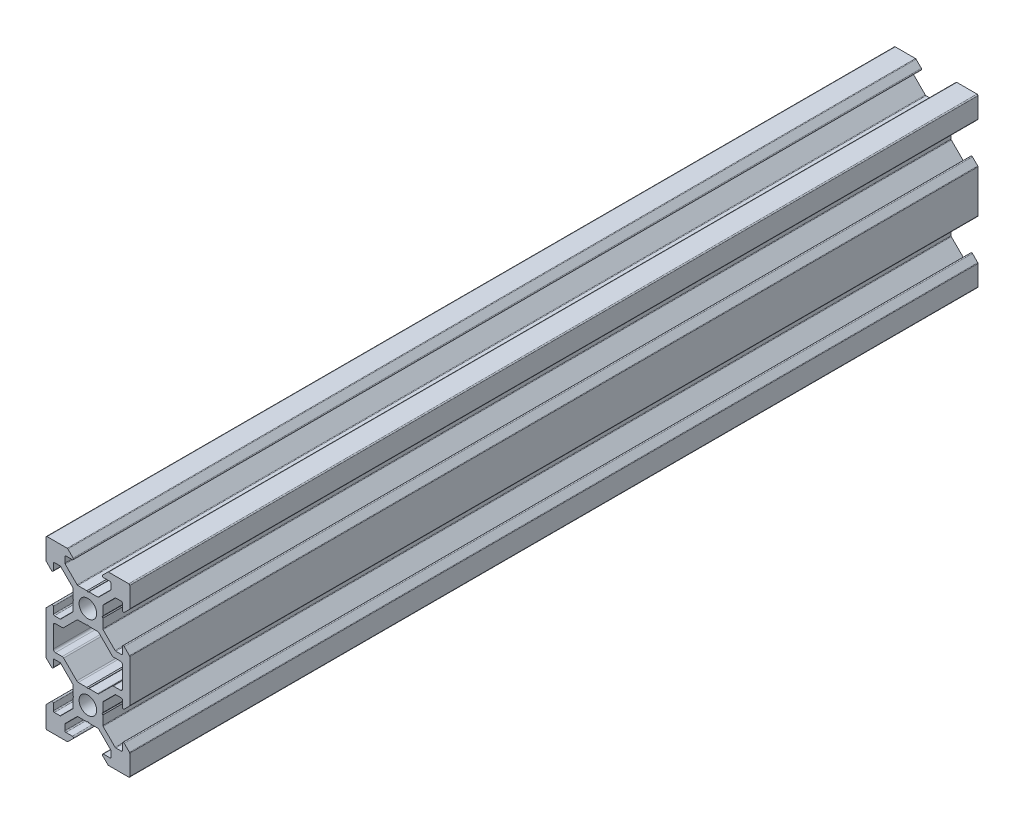
from build123d import *

# Parameters (mm, degrees)
SKETCH1_R           = 2.1
BOSS_EXTRUDE1_DEPTH = 202.56
FILLET1_R           = 0.25
FILLET2_R           = 0.5
CUT_EXTRUDE1_DEPTH  = 203.56


with BuildPart() as part:
    # Sketch1 → Boss-Extrude1 (new body)
    with BuildSketch(Plane.XY):
        Polygon((3.560660172, -2.5), (3.560660172, 2.5), (6.560660172, 5.5), (8.252142372, 5.5), (8.252142372, 3.1), (10, 4.847857628), (10, 10), (4.847857628, 10), (3.1, 8.252142372), (5.5, 8.252142372), (5.5, 6.560660172), (2.5, 3.560660172), (-2.5, 3.560660172), (-5.5, 6.560660172), (-5.5, 8.252142372), (-3.1, 8.252142372), (-4.847857628, 10), (-10, 10), (-10, 4.847857628), (-8.252142372, 3.1), (-8.252142372, 5.5), (-6.560660172, 5.5), (-3.560660172, 2.5), (-3.560660172, -2.5), (-6.560660172, -5.5), (-8.252142372, -5.5), (-8.252142372, -3.1), (-10, -4.847857628), (-10, -7), (-10, -13), (-10, -15.152142372), (-8.252142372, -16.9), (-8.252142372, -14.5), (-6.560660172, -14.5), (-3.560660172, -17.5), (-3.560660172, -22.5), (-6.560660172, -25.5), (-8.252142372, -25.5), (-8.252142372, -23.1), (-10, -24.847857628), (-10, -30), (-4.847857628, -30), (-3.1, -28.252142372), (-5.5, -28.252142372), (-5.5, -26.560660172), (-2.5, -23.560660172), (2.5, -23.560660172), (5.5, -26.560660172), (5.5, -28.252142372), (3.1, -28.252142372), (4.847857628, -30), (10, -30), (10, -24.847857628), (8.252142372, -23.1), (8.252142372, -25.5), (6.560660172, -25.5), (3.560660172, -22.5), (3.560660172, -17.5), (6.560660172, -14.5), (8.252142372, -14.5), (8.252142372, -16.9), (10, -15.152142372), (10, -13), (10, -7), (10, -4.847857628), (8.252142372, -3.1), (8.252142372, -5.5), (6.560660172, -5.5), align=None)
        Circle(SKETCH1_R, mode=Mode.SUBTRACT)
        with Locations((0, -20)):
            Circle(SKETCH1_R, mode=Mode.SUBTRACT)
        Polygon((2.5, -3.560660172), (-2.5, -3.560660172), (-5.5, -6.560660172), (-5.939339828, -7), (-8.252142372, -7), (-8.252142372, -13), (-5.939339828, -13), (-5.5, -13.439339828), (-2.5, -16.439339828), (2.5, -16.439339828), (5.5, -13.439339828), (5.939339828, -13), (8.252142372, -13), (8.252142372, -7), (5.939339828, -7), (5.5, -6.560660172), align=None, mode=Mode.SUBTRACT)
    extrude(amount=BOSS_EXTRUDE1_DEPTH)

    # Fillet1
    fillet1_edges = [part.edges().sort_by_distance(p)[0] for p in [
        (5.5, 6.560660172, 101.28),
        (5.5, 8.252142372, 101.28),
        (3.1, 8.252142372, 101.28),
        (4.847857628, 10, 101.28),
        (10, 10, 101.28),
        (10, 4.847857628, 101.28),
        (8.252142372, 3.1, 101.28),
        (8.252142372, 5.5, 101.28),
        (6.560660172, 5.5, 101.28),
        (3.560660172, 2.5, 101.28),
        (3.560660172, -2.5, 101.28),
        (6.560660172, -5.5, 101.28),
        (8.252142372, -5.5, 101.28),
        (8.252142372, -3.1, 101.28),
        (10, -4.847857628, 101.28),
        (10, -15.152142372, 101.28),
        (8.252142372, -16.9, 101.28),
        (8.252142372, -14.5, 101.28),
        (6.560660172, -14.5, 101.28),
        (3.560660172, -17.5, 101.28),
        (3.560660172, -22.5, 101.28),
        (6.560660172, -25.5, 101.28),
        (8.252142372, -25.5, 101.28),
        (8.252142372, -23.1, 101.28),
        (10, -24.847857628, 101.28),
        (10, -30, 101.28),
        (4.847857628, -30, 101.28),
        (3.1, -28.252142372, 101.28),
        (5.5, -28.252142372, 101.28),
        (5.5, -26.560660172, 101.28),
        (2.5, -23.560660172, 101.28),
        (-2.5, -23.560660172, 101.28),
        (-5.5, -26.560660172, 101.28),
        (-5.5, -28.252142372, 101.28),
        (-3.1, -28.252142372, 101.28),
        (-4.847857628, -30, 101.28),
        (-10, -30, 101.28),
        (-10, -24.847857628, 101.28),
        (-8.252142372, -23.1, 101.28),
        (-8.252142372, -25.5, 101.28),
        (-6.560660172, -25.5, 101.28),
        (-3.560660172, -22.5, 101.28),
        (-3.560660172, -17.5, 101.28),
        (-6.560660172, -14.5, 101.28),
        (-8.252142372, -14.5, 101.28),
        (-8.252142372, -16.9, 101.28),
        (-10, -15.152142372, 101.28),
        (-10, -4.847857628, 101.28),
        (-8.252142372, -3.1, 101.28),
        (-8.252142372, -5.5, 101.28),
        (-6.560660172, -5.5, 101.28),
        (-3.560660172, -2.5, 101.28),
        (-3.560660172, 2.5, 101.28),
        (-6.560660172, 5.5, 101.28),
        (-8.252142372, 5.5, 101.28),
        (-8.252142372, 3.1, 101.28),
        (-10, 4.847857628, 101.28),
        (-10, 10, 101.28),
        (-4.847857628, 10, 101.28),
        (-3.1, 8.252142372, 101.28),
        (-5.5, 8.252142372, 101.28),
        (-5.5, 6.560660172, 101.28),
        (-2.5, 3.560660172, 101.28),
        (2.5, 3.560660172, 101.28),
    ]]
    fillet(fillet1_edges, radius=FILLET1_R)

    # Fillet2
    fillet2_edges = [part.edges().sort_by_distance(p)[0] for p in [
        (-2.5, -3.560660172, 101.28),
        (-5.939339828, -7, 101.28),
        (-8.252142372, -7, 101.28),
        (-8.252142372, -13, 101.28),
        (-5.939339828, -13, 101.28),
        (-2.5, -16.439339828, 101.28),
        (2.5, -16.439339828, 101.28),
        (5.939339828, -13, 101.28),
        (8.252142372, -13, 101.28),
        (8.252142372, -7, 101.28),
        (5.939339828, -7, 101.28),
        (2.5, -3.560660172, 101.28),
    ]]
    fillet(fillet2_edges, radius=FILLET2_R)

    # Sketch2 → Cut-Extrude1 (cut, through all)
    with BuildSketch(Plane.XY.offset(202.56)):
        Polygon((0, 3.398953432), (-0.242280927, 3.560660172), (0.242280927, 3.560660172), align=None)
        Polygon((0, -3.398953432), (0.242280927, -3.560660172), (-0.242280927, -3.560660172), align=None)
        Polygon((3.560660172, 0.242280927), (3.560660172, -0.242280927), (3.398953432, 0), align=None)
        Polygon((-3.560660172, 0.242280927), (-3.560660172, -0.242280927), (-3.398953432, 0), align=None)
        Polygon((-3.398953432, -20), (-3.560660172, -20.242280927), (-3.560660172, -19.757719073), align=None)
        Polygon((3.398953432, -20), (3.560660172, -19.757719073), (3.560660172, -20.242280927), align=None)
        Polygon((-0.242280927, -16.439339828), (0.242280927, -16.439339828), (0, -16.601046568), align=None)
        Polygon((-0.242280927, -23.560660172), (0.242280927, -23.560660172), (0, -23.398953432), align=None)
    extrude(amount=-CUT_EXTRUDE1_DEPTH, mode=Mode.SUBTRACT)


solid = part.part
